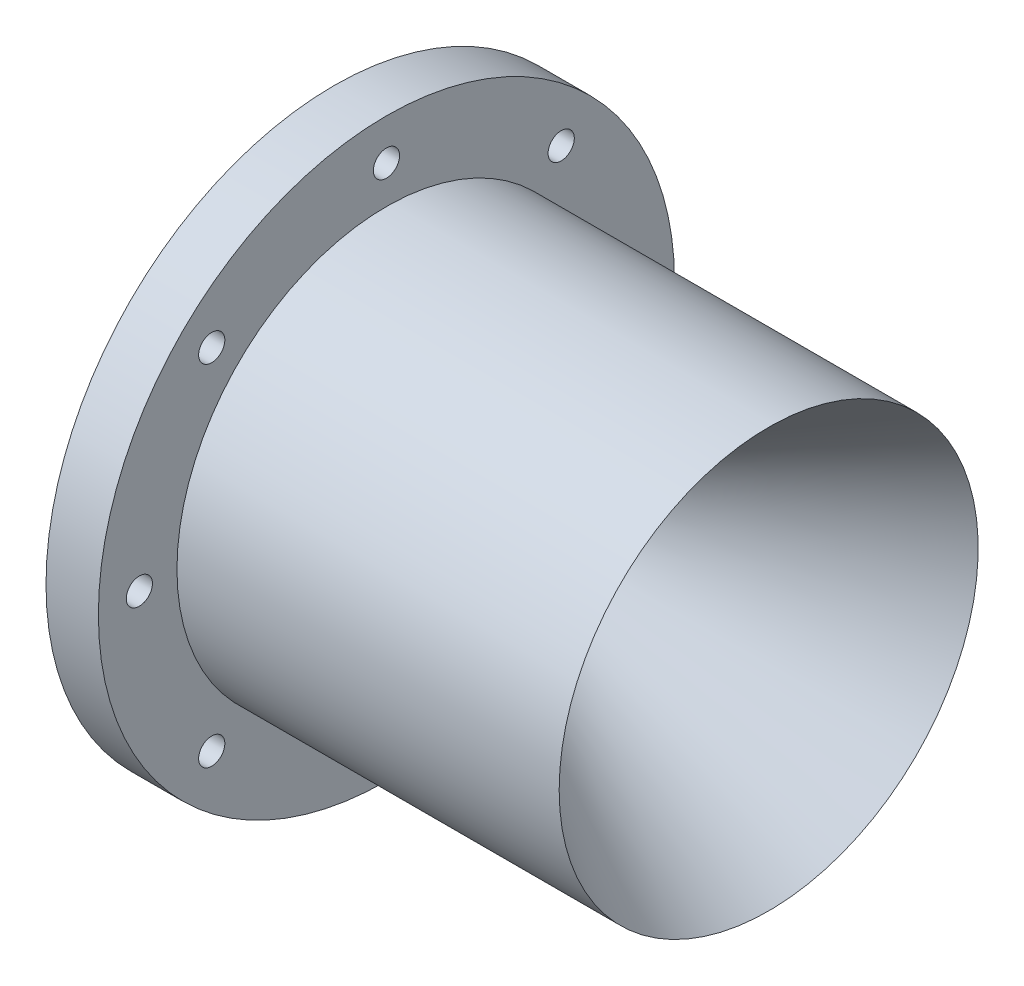
from build123d import *

# Parameters (mm, degrees)
SKETCH2_R          = 49.53
SKETCH2_R_2        = 47.625
CUT_EXTRUDE1_DEPTH = 1.1176
CUT_EXTRUDE2_REACH = 107.371
SKETCH3_R          = 3.175


with BuildPart() as part:
    # Sketch1 → Revolve1 (revolve)
    with BuildSketch(Plane.XY):
        Polygon((0, 7.9375), (72.324156056, 50.8), (-20.347266862, 50.8), (-20.347266862, 69.85), (-33.047266862, 69.85), (-33.047266862, 50.8), (-33.047266862, 41.275), (-12.7, 7.9375), align=None)
    revolve(axis=Axis((0, 0, 0), (1, 0, 0)))

    # Sketch2 → Cut-Extrude1 (cut)
    with BuildSketch(Plane.ZY.offset(33.047266862)):
        Circle(SKETCH2_R)
        Circle(SKETCH2_R_2, mode=Mode.SUBTRACT)
    extrude(amount=-CUT_EXTRUDE1_DEPTH, mode=Mode.SUBTRACT)

    # Sketch3 → Cut-Extrude2 (cut, up to next)
    with BuildSketch(Plane.ZY.offset(33.047266862), mode=Mode.PRIVATE) as cut_extrude2_sk1:
        with Locations((0, 59.9186)):
            Circle(SKETCH3_R)
    cut_extrude2_tool1 = extrude(cut_extrude2_sk1.sketch, amount=-CUT_EXTRUDE2_REACH, mode=Mode.PRIVATE) & part.part
    add(cut_extrude2_tool1.solids().sort_by_distance((-33.047267, 59.9186, 0))[0], mode=Mode.SUBTRACT)
    # Sketch3 → Cut-Extrude2 (cut, up to next)
    with BuildSketch(Plane.ZY.offset(33.047266862), mode=Mode.PRIVATE) as cut_extrude2_sk2:
        with Locations((42.368848379, 42.368848379)):
            Circle(SKETCH3_R)
    cut_extrude2_tool2 = extrude(cut_extrude2_sk2.sketch, amount=-CUT_EXTRUDE2_REACH, mode=Mode.PRIVATE) & part.part
    add(cut_extrude2_tool2.solids().sort_by_distance((-33.047267, 42.368848, 42.368848))[0], mode=Mode.SUBTRACT)
    # Sketch3 → Cut-Extrude2 (cut, up to next)
    with BuildSketch(Plane.ZY.offset(33.047266862), mode=Mode.PRIVATE) as cut_extrude2_sk3:
        with Locations((59.9186, 0)):
            Circle(SKETCH3_R)
    cut_extrude2_tool3 = extrude(cut_extrude2_sk3.sketch, amount=-CUT_EXTRUDE2_REACH, mode=Mode.PRIVATE) & part.part
    add(cut_extrude2_tool3.solids().sort_by_distance((-33.047267, 0, 59.9186))[0], mode=Mode.SUBTRACT)
    # Sketch3 → Cut-Extrude2 (cut, up to next)
    with BuildSketch(Plane.ZY.offset(33.047266862), mode=Mode.PRIVATE) as cut_extrude2_sk4:
        with Locations((42.368848379, -42.368848379)):
            Circle(SKETCH3_R)
    cut_extrude2_tool4 = extrude(cut_extrude2_sk4.sketch, amount=-CUT_EXTRUDE2_REACH, mode=Mode.PRIVATE) & part.part
    add(cut_extrude2_tool4.solids().sort_by_distance((-33.047267, -42.368848, 42.368848))[0], mode=Mode.SUBTRACT)
    # Sketch3 → Cut-Extrude2 (cut, up to next)
    with BuildSketch(Plane.ZY.offset(33.047266862), mode=Mode.PRIVATE) as cut_extrude2_sk5:
        with Locations((0, -59.9186)):
            Circle(SKETCH3_R)
    cut_extrude2_tool5 = extrude(cut_extrude2_sk5.sketch, amount=-CUT_EXTRUDE2_REACH, mode=Mode.PRIVATE) & part.part
    add(cut_extrude2_tool5.solids().sort_by_distance((-33.047267, -59.9186, 0))[0], mode=Mode.SUBTRACT)
    # Sketch3 → Cut-Extrude2 (cut, up to next)
    with BuildSketch(Plane.ZY.offset(33.047266862), mode=Mode.PRIVATE) as cut_extrude2_sk6:
        with Locations((-42.368848379, -42.368848379)):
            Circle(SKETCH3_R)
    cut_extrude2_tool6 = extrude(cut_extrude2_sk6.sketch, amount=-CUT_EXTRUDE2_REACH, mode=Mode.PRIVATE) & part.part
    add(cut_extrude2_tool6.solids().sort_by_distance((-33.047267, -42.368848, -42.368848))[0], mode=Mode.SUBTRACT)
    # Sketch3 → Cut-Extrude2 (cut, up to next)
    with BuildSketch(Plane.ZY.offset(33.047266862), mode=Mode.PRIVATE) as cut_extrude2_sk7:
        with Locations((-59.9186, 0)):
            Circle(SKETCH3_R)
    cut_extrude2_tool7 = extrude(cut_extrude2_sk7.sketch, amount=-CUT_EXTRUDE2_REACH, mode=Mode.PRIVATE) & part.part
    add(cut_extrude2_tool7.solids().sort_by_distance((-33.047267, 0, -59.9186))[0], mode=Mode.SUBTRACT)
    # Sketch3 → Cut-Extrude2 (cut, up to next)
    with BuildSketch(Plane.ZY.offset(33.047266862), mode=Mode.PRIVATE) as cut_extrude2_sk8:
        with Locations((-42.368848379, 42.368848379)):
            Circle(SKETCH3_R)
    cut_extrude2_tool8 = extrude(cut_extrude2_sk8.sketch, amount=-CUT_EXTRUDE2_REACH, mode=Mode.PRIVATE) & part.part
    add(cut_extrude2_tool8.solids().sort_by_distance((-33.047267, 42.368848, -42.368848))[0], mode=Mode.SUBTRACT)


solid = part.part
